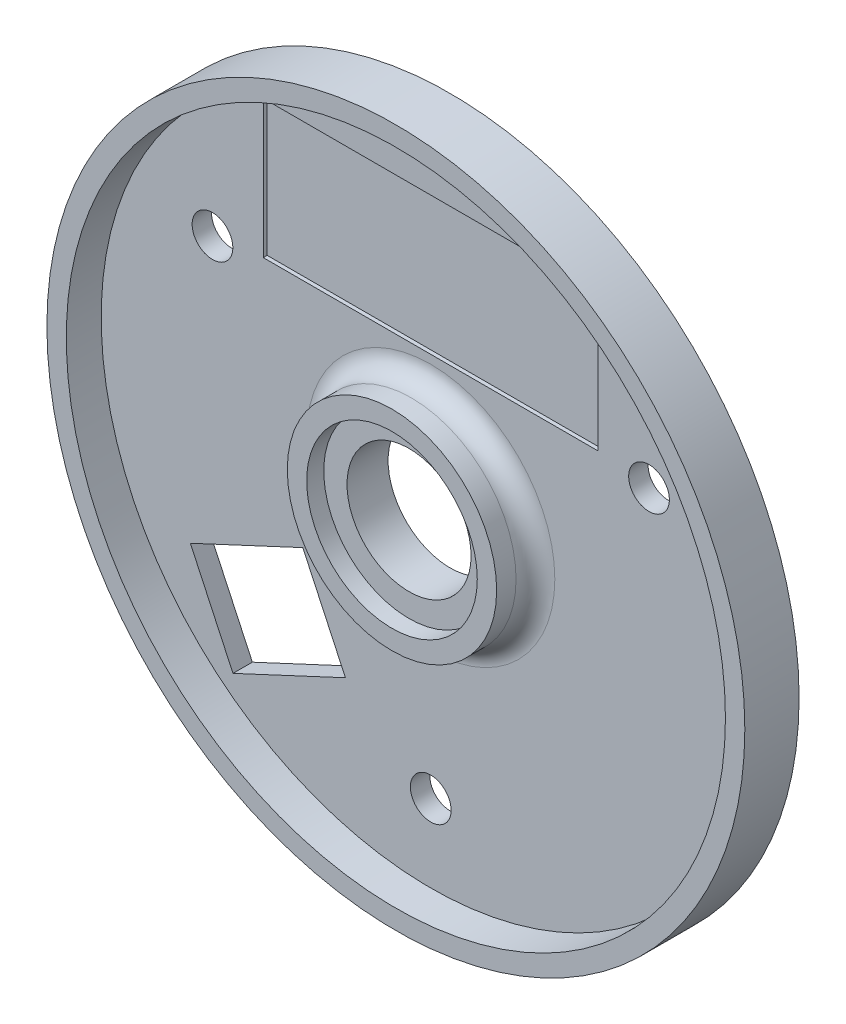
from build123d import *

# Parameters (mm, degrees)
SKETCH1_R               = 45
BOSS_EXTRUDE1_DEPTH     = 2.5
SKETCH2_R               = 45
SKETCH2_R_2             = 42.5
BOSS_EXTRUDE2_DEPTH     = 4.5
SKETCH3_R               = 8
CUT_EXTRUDE1_DEPTH      = 10
SKETCH5_R               = 13.5
SKETCH5_R_2             = 11
BOSS_EXTRUDE3_DEPTH     = 5
SKETCH7_W               = 43.18
SKETCH7_H               = 17.78
CUT_EXTRUDE2_DEPTH      = 0.5
CUT_EXTRUDE3_DEPTH      = 5
CUT_EXTRUDE4_DEPTH      = 0.5
SKETCH11_R              = 13.5
SKETCH11_R_2            = 8
BOSS_EXTRUDE4_DEPTH     = 2.8
SKETCH14_R              = 2.625
CUT_EXTRUDE5_DEPTH      = 6
CUT_EXTRUDE5_DEPTH_BACK = 3.5
FILLET1_R               = 2.5


with BuildPart() as part:
    # Sketch1 → Boss-Extrude1 (new body)
    with BuildSketch(Plane.XY):
        Circle(SKETCH1_R)
    extrude(amount=BOSS_EXTRUDE1_DEPTH)

    # Sketch2 → Boss-Extrude2 (add)
    with BuildSketch(Plane.XY.offset(2.5)):
        Circle(SKETCH2_R)
        Circle(SKETCH2_R_2, mode=Mode.SUBTRACT)
    extrude(amount=BOSS_EXTRUDE2_DEPTH)

    # Sketch3 → Cut-Extrude1 (cut)
    with BuildSketch(Plane.XY.offset(2.5)):
        Circle(SKETCH3_R)
    extrude(amount=-CUT_EXTRUDE1_DEPTH, mode=Mode.SUBTRACT)

    # Sketch5 → Boss-Extrude3 (add)
    with BuildSketch(Plane.XY.offset(2.5)):
        Circle(SKETCH5_R)
        Circle(SKETCH5_R_2, mode=Mode.SUBTRACT)
    extrude(amount=BOSS_EXTRUDE3_DEPTH)

    # Sketch7 → Cut-Extrude2 (cut)
    with BuildSketch(Plane.XY.offset(2.5)):
        with Locations((0, 26)):
            Rectangle(SKETCH7_W, SKETCH7_H)
    extrude(amount=-CUT_EXTRUDE2_DEPTH, mode=Mode.SUBTRACT)

    # Sketch8 → Cut-Extrude3 (cut)
    with BuildSketch(Plane.XY.offset(2.5)):
        Polygon((-16.496556405, -12.72805329), (-11.002519002, -24.510054522), (-25.503443595, -31.27194671), (-30.997480998, -19.489945478), align=None)
    extrude(amount=-CUT_EXTRUDE3_DEPTH, mode=Mode.SUBTRACT)

    # Sketch9 → Cut-Extrude4 (cut)
    with BuildSketch(Plane(origin=(0, 0, 0), x_dir=(-1, 0, 0), z_dir=(0, 0, -1))):
        Polygon((27.250107322, -13.32900476), (27.884034715, -11.969543079), (29.923227236, -12.920434168), (30.874118325, -10.881241647), (32.233580005, -11.51516904), (31.282688916, -13.554361561), (33.321881437, -14.505252649), (32.687954045, -15.86471433), (30.648761524, -14.913823241), (29.697870435, -16.953015762), (28.338408754, -16.319088369), (29.289299843, -14.279895849), align=None)
        Polygon((18.187029452, -9.102822142), (18.820956845, -7.743360462), (24.258803567, -10.279070032), (23.624876174, -11.638531713), align=None)
    extrude(amount=-CUT_EXTRUDE4_DEPTH, mode=Mode.SUBTRACT)

    # Sketch11 → Boss-Extrude4 (add)
    with BuildSketch(Plane.XY.offset(2.5)):
        Circle(SKETCH11_R)
        Circle(SKETCH11_R_2, mode=Mode.SUBTRACT)
    extrude(amount=BOSS_EXTRUDE4_DEPTH)

    # Sketch14 → Cut-Extrude5 (cut, two sides)
    with BuildSketch(Plane.XY.offset(2.5)) as cut_extrude5_sk:
        with Locations((0, -32.5)):
            Circle(SKETCH14_R)
        with Locations((-28.145825623, 16.25)):
            Circle(SKETCH14_R)
        with Locations((28.145825623, 16.25)):
            Circle(SKETCH14_R)
    extrude(amount=CUT_EXTRUDE5_DEPTH, mode=Mode.SUBTRACT)
    extrude(cut_extrude5_sk.sketch, amount=-CUT_EXTRUDE5_DEPTH_BACK, mode=Mode.SUBTRACT)

    # Fillet1
    fillet1_edges = [part.edges().sort_by_distance(p)[0] for p in [
        (-13.5, 0, 2.5),
    ]]
    fillet(fillet1_edges, radius=FILLET1_R)


solid = part.part
